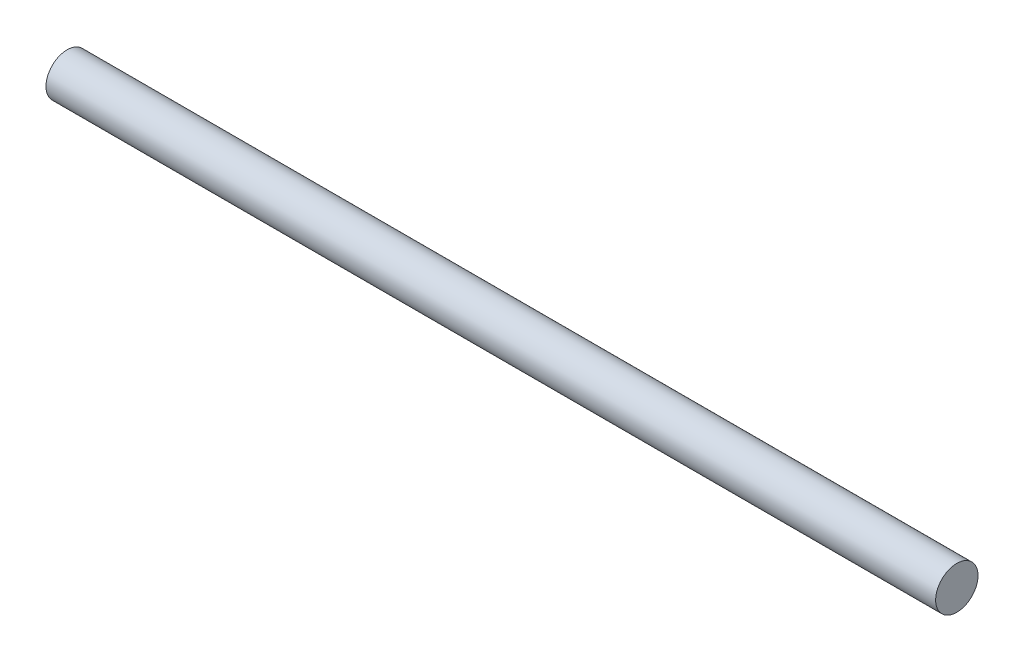
from build123d import *

# Parameters (mm, degrees)
CROQUIS1_R              = 9.525
SALIENTE_EXTRUIR1_DEPTH = 400
CROQUIS2_R              = 4.7625
CORTAR_EXTRUIR1_DEPTH   = 30


with BuildPart() as part:
    # Croquis1 → Saliente-Extruir1 (new body)
    with BuildSketch(Plane(origin=(0, 0, 0), x_dir=(0, 0, -1), z_dir=(1, 0, 0))):
        Circle(CROQUIS1_R)
    extrude(amount=SALIENTE_EXTRUIR1_DEPTH)

    # Croquis2 → Cortar-Extruir1 (cut)
    with BuildSketch(Plane.ZY):
        Circle(CROQUIS2_R)
    extrude(amount=-CORTAR_EXTRUIR1_DEPTH, mode=Mode.SUBTRACT)


solid = part.part
